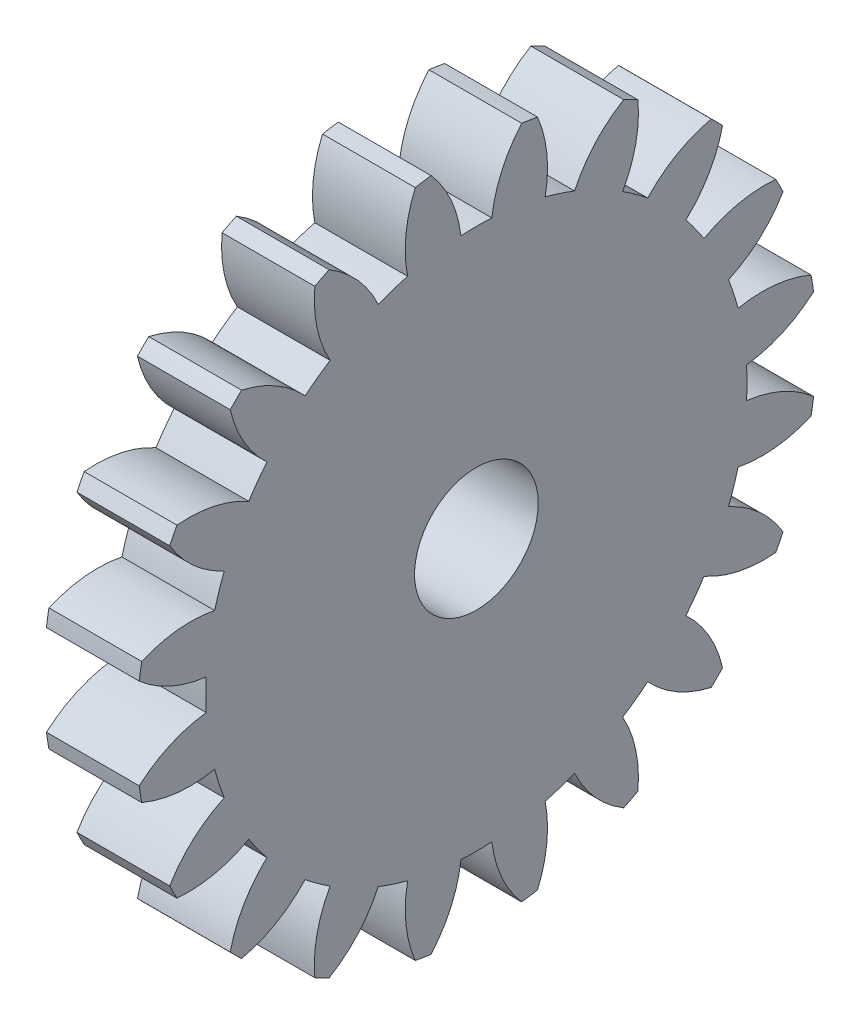
from build123d import *

# Parameters (mm, degrees)
BASPROSKE_W        = 3
BASPROSKE_H        = 11
TOOTHCUT_DEPTH     = 16.842979518
TEETHCUTS_COUNT    = 20
TEETHCUTS_ANGLE    = 342
BORSKE_R           = 1.5
BORE_DEPTH         = 50.0000508
SKETCH1_R          = 2
CUT_EXTRUDE1_DEPTH = 16.706934942


with BuildPart() as part:
    # BasProSke → Base-Revolve (revolve)
    with BuildSketch(Plane(origin=(0, 0, 0), x_dir=(1, 0, 0), z_dir=(0, 1, 0)), mode=Mode.PRIVATE) as base_revolve_sk:
        with Locations((1.5, 5.5)):
            Rectangle(BASPROSKE_W, BASPROSKE_H)
    revolve(base_revolve_sk.sketch.rotate(Axis((-10, 0, 0), (1, 0, 0)), 180), axis=Axis((-10, 0, 0), (1, 0, 0)))

    # TooCutSke → ToothCut (cut, through all)
    with BuildSketch(Plane(origin=(0, 0, 0), x_dir=(0, 0, -1), z_dir=(1, 0, 0))):
        with BuildLine():
            ThreePointArc((0.499924007, 8.734705318), (0, 8.749), (-0.499924007, 8.734705318))
            ThreePointArc((-0.499924007, 8.734705318), (-0.824302243, 9.905497836), (-1.485192705, 10.924909509))
            ThreePointArc((-1.485192705, 10.924909509), (0, 11.0254), (1.485192705, 10.924909509))
            ThreePointArc((1.485192705, 10.924909509), (0.824302243, 9.905497836), (0.499924007, 8.734705318))
        make_face()
    toothcut = extrude(amount=TOOTHCUT_DEPTH, mode=Mode.SUBTRACT)

    # TeethCuts: ToothCut ×20 about axis
    teethcuts_axis = Axis((-10, 0, 0), (1, 0, 0))
    for i in range(1, TEETHCUTS_COUNT):
        add(toothcut.rotate(teethcuts_axis, i * TEETHCUTS_ANGLE / (TEETHCUTS_COUNT - 1)), mode=Mode.SUBTRACT)

    # BorSke → Bore (cut, symmetric)
    with BuildSketch(Plane(origin=(0, 0, 0), x_dir=(0, 0, -1), z_dir=(1, 0, 0))):
        with Locations(Location((0, 0, 0), (0, 0, 180))):
            Circle(BORSKE_R)
    extrude(amount=BORE_DEPTH, both=True, mode=Mode.SUBTRACT)

    # Sketch1 → Cut-Extrude1 (cut, through all)
    with BuildSketch(Plane(origin=(3, 0, 0), x_dir=(0, 0, -1), z_dir=(1, 0, 0))):
        Circle(SKETCH1_R)
    extrude(amount=-CUT_EXTRUDE1_DEPTH, mode=Mode.SUBTRACT)


solid = part.part
